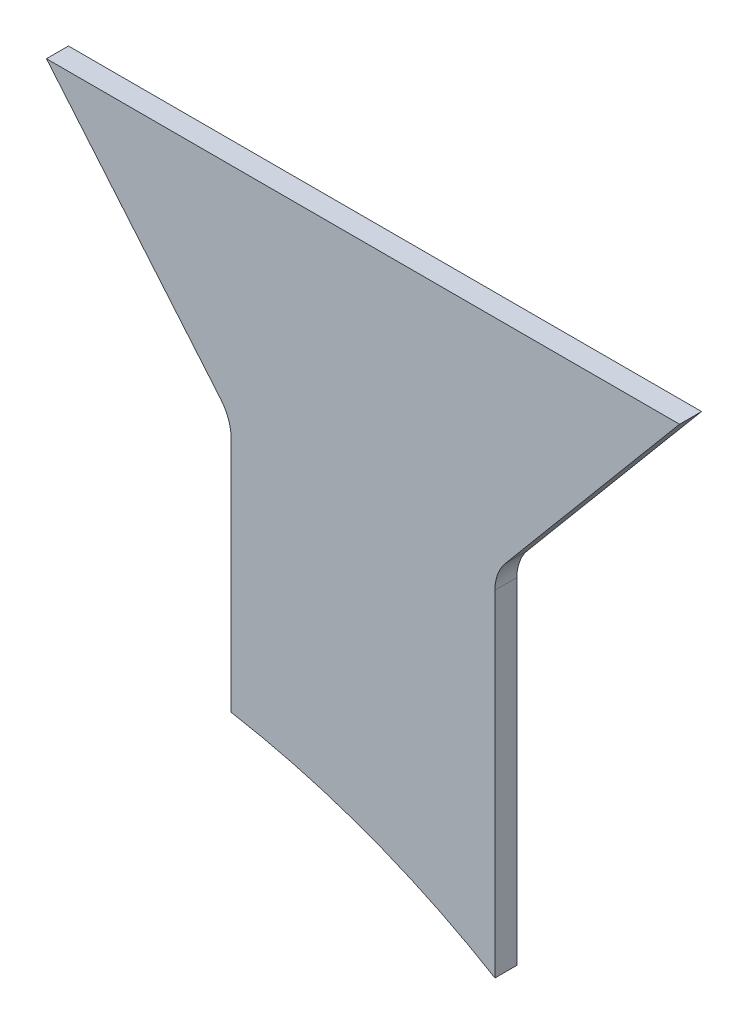
from build123d import *

# Parameters (mm, degrees)
FUNNEL_SIDE_PANEL_DEPTH = 5
FILLET1_R               = 10


with BuildPart() as part:
    # Sketch1 → Funnel - Side Panel (new body)
    with BuildSketch(Plane.XY):
        with BuildLine():
            Line((30, 0), (30, 80))
            Line((30, 80), (71.974030913, 130.022702136))
            Line((71.974030913, 130.022702136), (-71.974030913, 130.022702136))
            Line((-71.974030913, 130.022702136), (-30, 80))
            Line((-30, 80), (-30, 22.326086298))
            ThreePointArc((-30, 22.326086298), (1.02961193, 13.930062634), (30, 0))
        make_face()
    extrude(amount=FUNNEL_SIDE_PANEL_DEPTH)

    # Fillet1
    fillet1_edges = [part.edges().sort_by_distance(p)[0] for p in [
        (-30, 80, 2.5),
        (30, 80, 2.5),
    ]]
    fillet(fillet1_edges, radius=FILLET1_R)


solid = part.part
